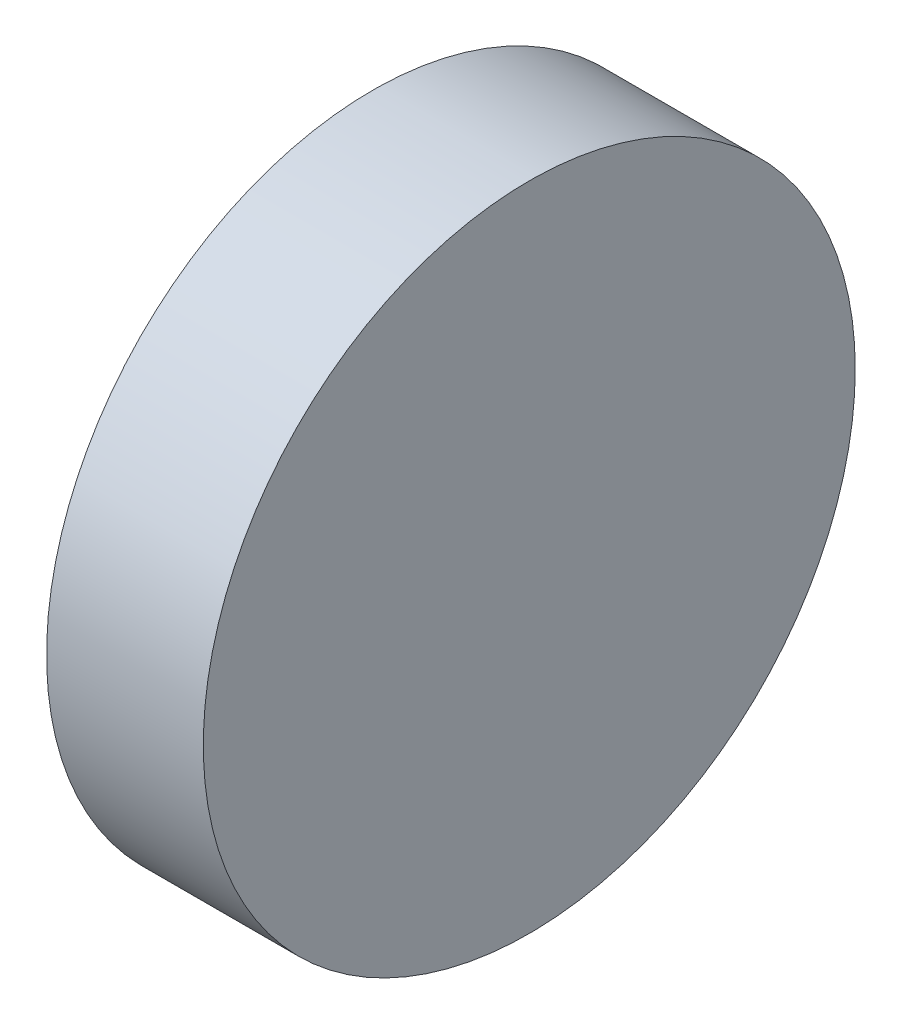
from build123d import *

# Parameters (mm, degrees)
SKETCH1_R           = 41.596961702
BOSS_EXTRUDE1_DEPTH = 10


with BuildPart() as part:
    # Sketch1 → Boss-Extrude1 (new body, symmetric)
    with BuildSketch(Plane(origin=(0, 0, 0), x_dir=(0, 0, -1), z_dir=(1, 0, 0))):
        Circle(SKETCH1_R)
    extrude(amount=BOSS_EXTRUDE1_DEPTH, both=True)


solid = part.part
